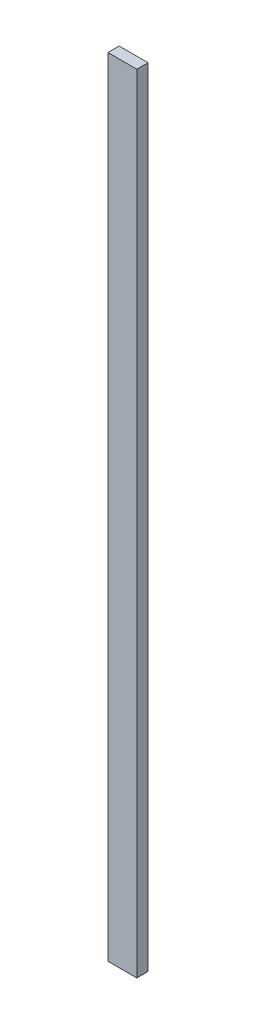
from build123d import *

# Parameters (mm, degrees)
SKETCH1_W           = 25.741687798
SKETCH1_H           = 700
BOSS_EXTRUDE1_DEPTH = 10


with BuildPart() as part:
    # Sketch1 → Boss-Extrude1 (new body)
    with BuildSketch(Plane.XY):
        with Locations((-56.693002888, 294.992464765)):
            Rectangle(SKETCH1_W, SKETCH1_H)
    extrude(amount=BOSS_EXTRUDE1_DEPTH)


solid = part.part
